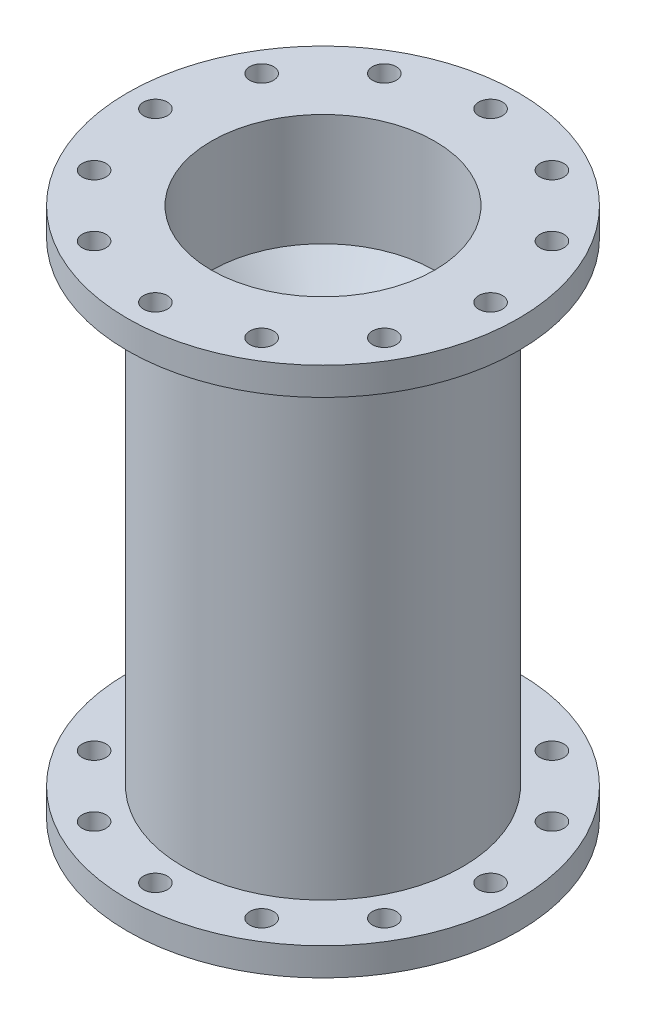
from build123d import *

# Parameters (mm, degrees)
F_3_0_213_DIAMETER_HOLE3_D = 5.4102


with BuildPart() as part:
    # Sketch1 → Chamber (revolve)
    with BuildSketch(Plane(origin=(0, 0, 0), x_dir=(0, 0, -1), z_dir=(1, 0, 0))):
        Polygon((31.75, 6.35), (31.75, 114.3), (44.45, 114.3), (44.45, 120.65), (31.75, 120.65), (25.4, 120.65), (25.4, 114.3), (25.4, 6.35), (25.4, 0), (31.75, 0), (44.45, 0), (44.45, 6.35), align=None)
    revolve(axis=Axis((0, 0, 0), (0, 1, 0)))

    # Sketch4 → Turbulence Rings (revolve)
    with BuildSketch(Plane(origin=(0, 0, 0), x_dir=(0, 0, -1), z_dir=(1, 0, 0))):
        Polygon((25.4, 92.643708368), (25.4, 95.183708368), (7.62, 77.403708368), (7.62, 74.863708368), align=None)
    revolve(axis=Axis((0, 0, 0), (0, 1, 0)))

    # #3 (0.213) Diameter Hole3 (through all)
    with Locations(Plane(origin=(0, 120.65, 0), x_dir=(1, 0, 0), z_dir=(0, 1, 0))):
        with Locations((0, 0), (-38.1, 0), (-32.995567884, 19.05), (-19.05, 32.995567884), (0, 38.1), (19.05, 32.995567884), (32.995567884, 19.05), (38.1, 0), (32.995567884, -19.05), (19.05, -32.995567884), (0, -38.1), (-19.05, -32.995567884), (-32.995567884, -19.05)):
            Hole(F_3_0_213_DIAMETER_HOLE3_D / 2)


solid = part.part
